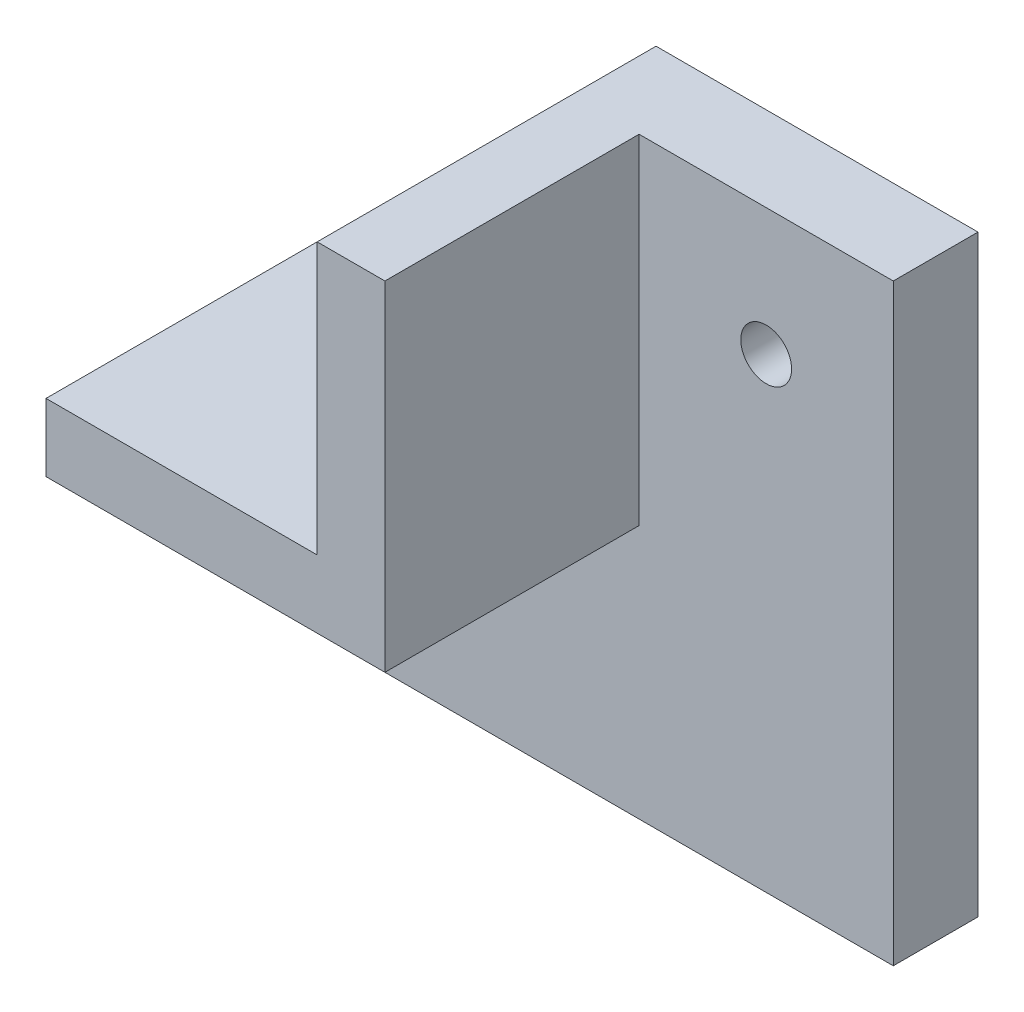
from build123d import *

# Parameters (mm, degrees)
BOSS_EXTRUDE1_DEPTH = 5
BOSS_EXTRUDE2_DEPTH = 20
SKETCH3_W           = 20
SKETCH3_H           = 15
CUT_EXTRUDE1_DEPTH  = 21
SKETCH4_R           = 1.5
CUT_EXTRUDE2_DEPTH  = 21


with BuildPart() as part:
    # Sketch1 → Boss-Extrude1 (new body)
    with BuildSketch(Plane.XY):
        Polygon((14.31372549, -4.264705882), (34.31372549, -4.264705882), (34.31372549, -19.264705882), (-20.68627451, -19.264705882), (-20.68627451, -4.264705882), (-0.68627451, -4.264705882), (-0.68627451, 15.735294118), (14.31372549, 15.735294118), align=None)
    extrude(amount=BOSS_EXTRUDE1_DEPTH)

    # Sketch2 → Boss-Extrude2 (add)
    with BuildSketch(Plane(origin=(0, 0, 0), x_dir=(-1, 0, 0), z_dir=(0, 0, -1))):
        Polygon((0.68627451, 15.735294118), (4.68627451, 15.735294118), (4.68627451, -0.264705882), (6.079970528, -0.264705882), (20.68627451, -0.264705882), (20.68627451, -4.264705882), (0.68627451, -4.264705882), align=None)
    extrude(amount=-BOSS_EXTRUDE2_DEPTH)

    # Sketch3 → Cut-Extrude1 (cut, through all)
    with BuildSketch(Plane(origin=(0, 0, 0), x_dir=(-1, 0, 0), z_dir=(0, 0, -1))):
        with Locations((-24.31372549, -11.764705882)):
            Rectangle(SKETCH3_W, SKETCH3_H)
    extrude(amount=-CUT_EXTRUDE1_DEPTH, mode=Mode.SUBTRACT)

    # Sketch4 → Cut-Extrude2 (cut, through all)
    with BuildSketch(Plane(origin=(0, 0, 0), x_dir=(-1, 0, 0), z_dir=(0, 0, -1))):
        with Locations((-6.81372549, 8.235294118)):
            Circle(SKETCH4_R)
        with Locations((13.18627451, -11.764705882)):
            Circle(SKETCH4_R)
    extrude(amount=-CUT_EXTRUDE2_DEPTH, mode=Mode.SUBTRACT)


solid = part.part
